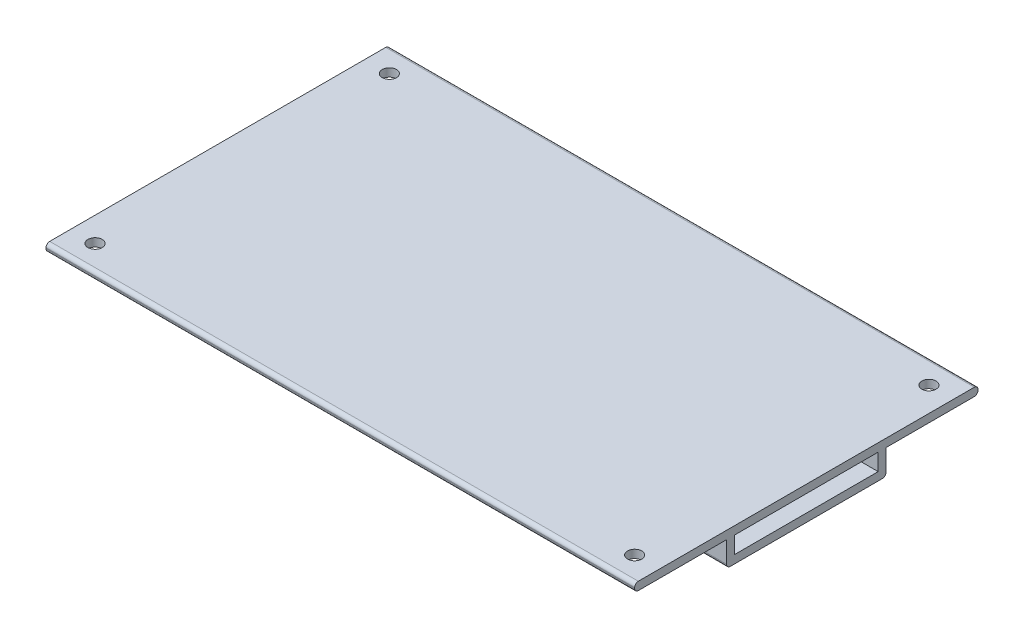
from build123d import *

# Parameters (mm, degrees)
SKETCH1_W           = 29.3
SKETCH1_H           = 3.44
BOSS_EXTRUDE1_DEPTH = 120
FILLET1_R           = 0.75
CUT_EXTRUDE1_REACH  = 8.76
SKETCH2_R           = 1.45


with BuildPart() as part:
    # Sketch1 → Boss-Extrude1 (new body)
    with BuildSketch(Plane(origin=(0, 0, 0), x_dir=(0, 0, -1), z_dir=(1, 0, 0))):
        Polygon((-16.25, 0), (-16.25, 5.1), (-35, 5.1), (-35, 6.76), (35, 6.76), (35, 5.1), (16.25, 5.1), (16.25, 0), align=None)
        with Locations((0, 3.38)):
            Rectangle(SKETCH1_W, SKETCH1_H, mode=Mode.SUBTRACT)
    extrude(amount=BOSS_EXTRUDE1_DEPTH)

    # Fillet1
    fillet1_edges = [part.edges().sort_by_distance(p)[0] for p in [
        (60, 0, 16.25),
        (60, 5.1, 35),
        (60, 6.76, 35),
        (60, 6.76, -35),
        (60, 5.1, -35),
        (60, 0, -16.25),
    ]]
    fillet(fillet1_edges, radius=FILLET1_R)

    # Sketch2 → Cut-Extrude1 (cut, up to next)
    with BuildSketch(Plane(origin=(0, 6.76, 0), x_dir=(1, 0, 0), z_dir=(0, 1, 0)), mode=Mode.PRIVATE) as cut_extrude1_sk1:
        with Locations((115, 30)):
            Circle(SKETCH2_R)
    cut_extrude1_tool1 = extrude(cut_extrude1_sk1.sketch, amount=-CUT_EXTRUDE1_REACH, mode=Mode.PRIVATE) & part.part
    add(cut_extrude1_tool1.solids().sort_by_distance((115, 6.76, -30))[0], mode=Mode.SUBTRACT)
    # Sketch2 → Cut-Extrude1 (cut, up to next)
    with BuildSketch(Plane(origin=(0, 6.76, 0), x_dir=(1, 0, 0), z_dir=(0, 1, 0)), mode=Mode.PRIVATE) as cut_extrude1_sk2:
        with Locations((5, 30)):
            Circle(SKETCH2_R)
    cut_extrude1_tool2 = extrude(cut_extrude1_sk2.sketch, amount=-CUT_EXTRUDE1_REACH, mode=Mode.PRIVATE) & part.part
    add(cut_extrude1_tool2.solids().sort_by_distance((5, 6.76, -30))[0], mode=Mode.SUBTRACT)
    # Sketch2 → Cut-Extrude1 (cut, up to next)
    with BuildSketch(Plane(origin=(0, 6.76, 0), x_dir=(1, 0, 0), z_dir=(0, 1, 0)), mode=Mode.PRIVATE) as cut_extrude1_sk3:
        with Locations((5, -30)):
            Circle(SKETCH2_R)
    cut_extrude1_tool3 = extrude(cut_extrude1_sk3.sketch, amount=-CUT_EXTRUDE1_REACH, mode=Mode.PRIVATE) & part.part
    add(cut_extrude1_tool3.solids().sort_by_distance((5, 6.76, 30))[0], mode=Mode.SUBTRACT)
    # Sketch2 → Cut-Extrude1 (cut, up to next)
    with BuildSketch(Plane(origin=(0, 6.76, 0), x_dir=(1, 0, 0), z_dir=(0, 1, 0)), mode=Mode.PRIVATE) as cut_extrude1_sk4:
        with Locations((115, -30)):
            Circle(SKETCH2_R)
    cut_extrude1_tool4 = extrude(cut_extrude1_sk4.sketch, amount=-CUT_EXTRUDE1_REACH, mode=Mode.PRIVATE) & part.part
    add(cut_extrude1_tool4.solids().sort_by_distance((115, 6.76, 30))[0], mode=Mode.SUBTRACT)


solid = part.part
